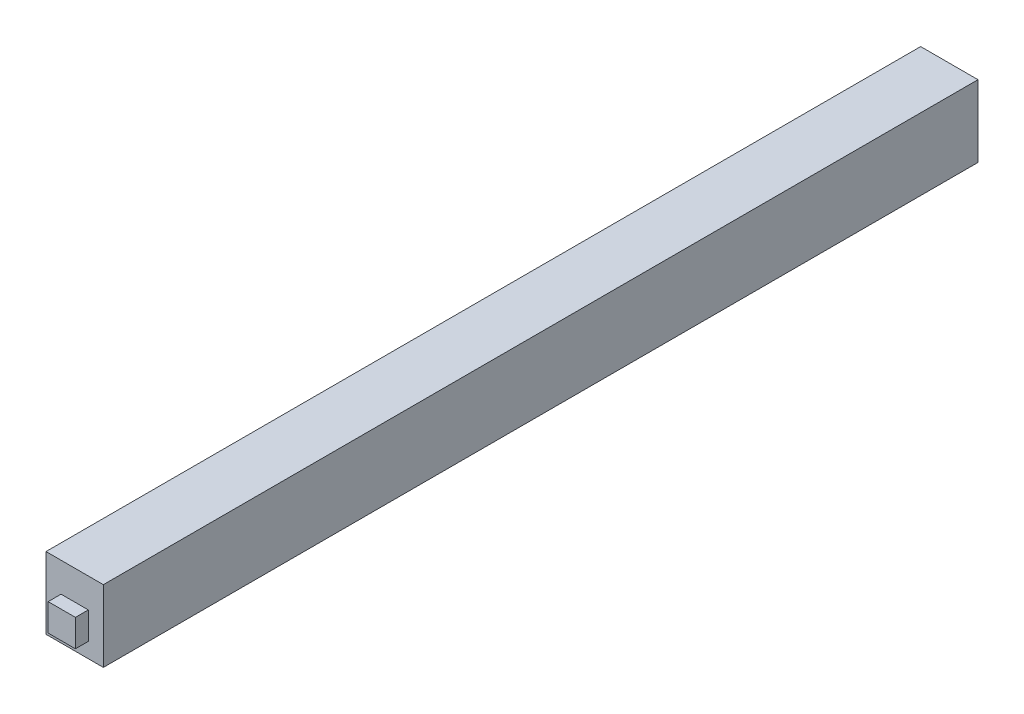
from build123d import *

# Parameters (mm, degrees)
SKETCH1_W           = 8
SKETCH1_H           = 10
BOSS_EXTRUDE1_DEPTH = 122
SKETCH2_W           = 3.8
SKETCH2_H           = 3.8
BOSS_EXTRUDE2_DEPTH = 1.8
SKETCH3_W           = 3.8
SKETCH3_H           = 3.8
BOSS_EXTRUDE3_DEPTH = 1.8


with BuildPart() as part:
    # Sketch1 → Boss-Extrude1 (new body)
    with BuildSketch(Plane.XY):
        with Locations((4, 5)):
            Rectangle(SKETCH1_W, SKETCH1_H)
    extrude(amount=BOSS_EXTRUDE1_DEPTH)

    # Sketch2 → Boss-Extrude2 (add)
    with BuildSketch(Plane(origin=(0, 0, 0), x_dir=(-1, 0, 0), z_dir=(0, 0, -1))):
        with Locations((-4, 4)):
            Rectangle(SKETCH2_W, SKETCH2_H)
    extrude(amount=BOSS_EXTRUDE2_DEPTH)

    # Sketch3 → Boss-Extrude3 (add)
    with BuildSketch(Plane.XY.offset(122)):
        with Locations((4, 4)):
            Rectangle(SKETCH3_W, SKETCH3_H)
    extrude(amount=BOSS_EXTRUDE3_DEPTH)


solid = part.part
